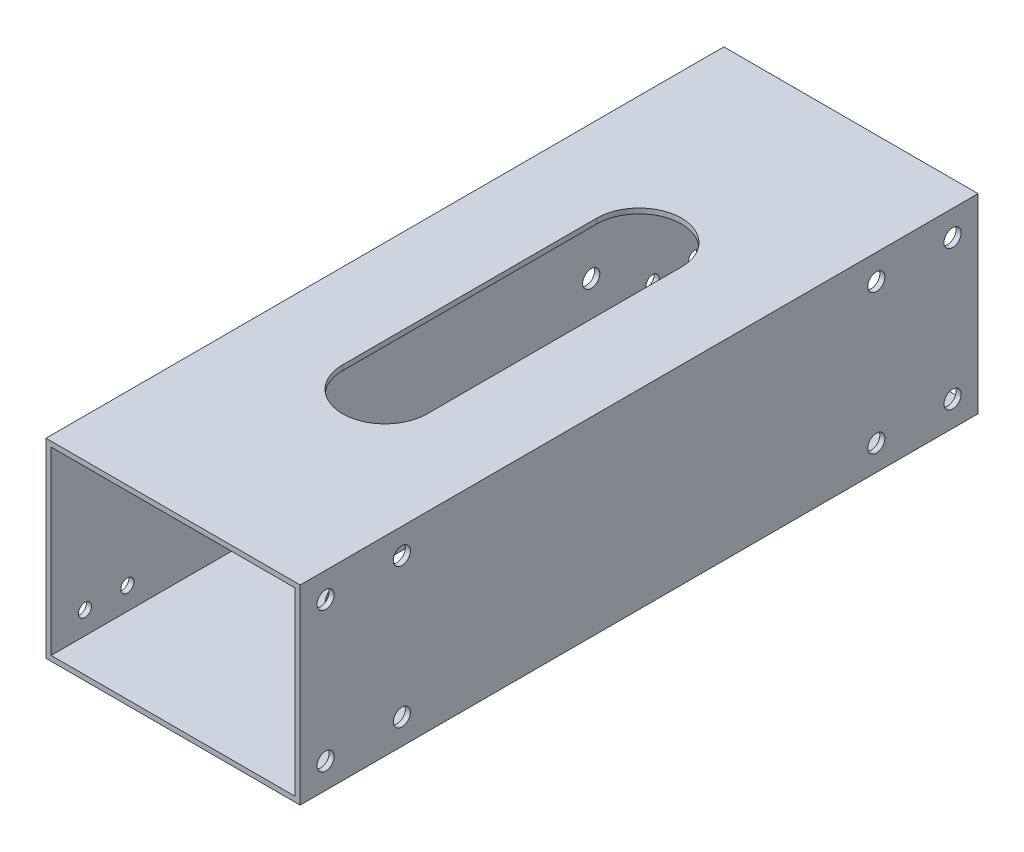
from build123d import *

# Parameters (mm, degrees)
SKETCH_1_W          = 60
SKETCH_1_H          = 45
SKETCH_1_W_2        = 57.6
SKETCH_1_H_2        = 42.6
EXTRUDE_1_DEPTH     = 80
SKETCH_4_R          = 2.025
CUT_EXTRUDE_1_DEPTH = 5
SKETCH_5_R          = 1.55
CUT_EXTRUDE_2_DEPTH = 5
SKETCH_6_R          = 2.025
CUT_EXTRUDE_3_DEPTH = 1.2
CUT_EXTRUDE_4_DEPTH = 160


with BuildPart() as part:
    # 草图1 → 凸台-拉伸1 (new body, symmetric)
    with BuildSketch(Plane.XY):
        Rectangle(SKETCH_1_W, SKETCH_1_H)
        Rectangle(SKETCH_1_W_2, SKETCH_1_H_2, mode=Mode.SUBTRACT)
    extrude(amount=EXTRUDE_1_DEPTH, both=True)

    # 草图4 → 切除-拉伸1 (cut, symmetric)
    with BuildSketch(Plane(origin=(30, 0, 0), x_dir=(0, 0, -1), z_dir=(1, 0, 0))):
        with Locations((-74, 16.5)):
            Circle(SKETCH_4_R)
        with Locations((-56, 16.5)):
            Circle(SKETCH_4_R)
        with Locations((-74, -16.5)):
            Circle(SKETCH_4_R)
        with Locations((-56, -16.5)):
            Circle(SKETCH_4_R)
    cut_extrude_1 = extrude(amount=CUT_EXTRUDE_1_DEPTH, both=True, mode=Mode.SUBTRACT)

    # 镜向1: 切除-拉伸1 across plane
    add(cut_extrude_1.mirror(Plane.XY), mode=Mode.SUBTRACT)

    # 草图5 → 切除-拉伸2 (cut, symmetric)
    with BuildSketch(Plane.ZY.offset(30)):
        with Locations((62, 16)):
            Circle(SKETCH_5_R)
        with Locations((72, 16)):
            Circle(SKETCH_5_R)
        with Locations((62, -16)):
            Circle(SKETCH_5_R)
        with Locations((72, -16)):
            Circle(SKETCH_5_R)
    cut_extrude_2 = extrude(amount=CUT_EXTRUDE_2_DEPTH, both=True, mode=Mode.SUBTRACT)

    # 镜向2: 切除-拉伸2 across plane
    add(cut_extrude_2.mirror(Plane.XY), mode=Mode.SUBTRACT)

    # 草图6 → 切除-拉伸3 (cut)
    with BuildSketch(Plane.ZY.offset(30)):
        with Locations((47.5, -8)):
            Circle(SKETCH_6_R)
        with Locations((47.5, 17)):
            Circle(SKETCH_6_R)
        with Locations((-47.5, 17)):
            Circle(SKETCH_6_R)
        with Locations((-47.5, -8)):
            Circle(SKETCH_6_R)
    extrude(amount=-CUT_EXTRUDE_3_DEPTH, mode=Mode.SUBTRACT)

    # 草图7 → 切除-拉伸4 (cut)
    with BuildSketch(Plane.XZ.offset(22.5)):
        with BuildLine():
            Line((-10, -30), (-10, 30))
            ThreePointArc((-10, 30), (0, 40), (10, 30))
            Line((10, 30), (10, -30))
            ThreePointArc((10, -30), (0, -40), (-10, -30))
        make_face()
    extrude(amount=-CUT_EXTRUDE_4_DEPTH, mode=Mode.SUBTRACT)


solid = part.part
